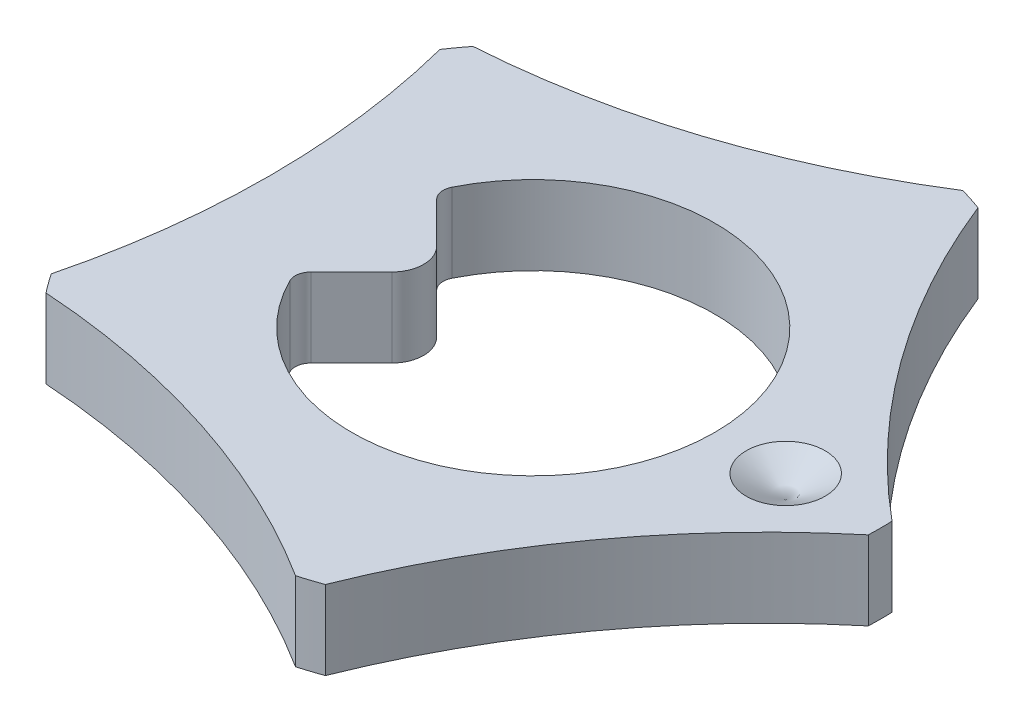
from build123d import *

# Parameters (mm, degrees)
SKETCH2_R           = 2.2
BOSS_EXTRUDE2_DEPTH = 0.5
SKETCH3_OUTSIDE_W   = 7.648
SKETCH3_OUTSIDE_H   = 7.648
CUT_EXTRUDE1_DEPTH  = 0.5
CUT_EXTRUDE2_REACH  = 2.5
FILLET1_R           = 0.2
FILLET2_R           = 0.1


with BuildPart() as part:
    # Sketch2 → Boss-Extrude2 (new body)
    with BuildSketch(Plane(origin=(0, 0, 0), x_dir=(1, 0, 0), z_dir=(0, 1, 0))):
        Circle(SKETCH2_R)
    extrude(amount=BOSS_EXTRUDE2_DEPTH)

    # Sketch3 outside → Cut-Extrude1 (cut)
    with BuildSketch(Plane(origin=(0, 0.5, 0), x_dir=(1, 0, 0), z_dir=(0, 1, 0))):
        Rectangle(SKETCH3_OUTSIDE_W, SKETCH3_OUTSIDE_H)
        with BuildLine():
            ThreePointArc((0.750757799, 2.067936829), (1.350081886, 0.980891906), (2.198721715, 0.074985473))
            ThreePointArc((2.198721715, 0.074985473), (2.2, 0), (2.198721715, -0.074985473))
            ThreePointArc((2.198721715, -0.074985473), (1.350081886, -0.980891906), (0.750757799, -2.067936829))
            ThreePointArc((0.750757799, -2.067936829), (0.679837388, -2.092324336), (0.608126953, -2.1142804))
            ThreePointArc((0.608126953, -2.1142804), (-0.515685393, -1.587116444), (-1.734727878, -1.35304072))
            ThreePointArc((-1.734727878, -1.35304072), (-1.779837388, -1.293127555), (-1.822878589, -1.231711675))
            ThreePointArc((-1.822878589, -1.231711675), (-1.668792986, 0), (-1.822878589, 1.231711675))
            ThreePointArc((-1.822878589, 1.231711675), (-1.779837388, 1.293127555), (-1.734727878, 1.35304072))
            ThreePointArc((-1.734727878, 1.35304072), (-0.515685393, 1.587116444), (0.608126953, 2.1142804))
            ThreePointArc((0.608126953, 2.1142804), (0.679837388, 2.092324336), (0.750757799, 2.067936829))
        make_face(mode=Mode.SUBTRACT)
    extrude(amount=-CUT_EXTRUDE1_DEPTH, mode=Mode.SUBTRACT)

    # Sketch4 → Cut-Extrude2 (cut, up to next)
    with BuildSketch(Plane(origin=(0, 0.5, 0), x_dir=(1, 0, 0), z_dir=(0, 1, 0)), mode=Mode.PRIVATE) as cut_extrude2_sk1:
        with BuildLine():
            Line((-1.059401619, 0.447401619), (-0.612, 0))
            Line((-0.612, 0), (-1.059401619, -0.447401619))
            ThreePointArc((-1.059401619, -0.447401619), (1.15, 0), (-1.059401619, 0.447401619))
        make_face()
    cut_extrude2_tool1 = extrude(cut_extrude2_sk1.sketch, amount=-CUT_EXTRUDE2_REACH, mode=Mode.PRIVATE) & part.part
    add(cut_extrude2_tool1.solids().sort_by_distance((0.062027, 0.5, 0))[0], mode=Mode.SUBTRACT)

    # Fillet1
    fillet1_edges = [part.edges().sort_by_distance(p)[0] for p in [
        (-0.612, 0.25, 0),
    ]]
    fillet(fillet1_edges, radius=FILLET1_R)

    # Fillet2
    fillet2_edges = [part.edges().sort_by_distance(p)[0] for p in [
        (-1.059401619, 0.25, -0.447401619),
        (-1.059401619, 0.25, 0.447401619),
    ]]
    fillet(fillet2_edges, radius=FILLET2_R)

    # Sketch6 → Cut-Revolve7 (revolve, cut)
    with BuildSketch(Plane.XY):
        Polygon((1.6, 0.5), (1.6, 0.355662433), (1.85, 0.5), align=None)
    revolve(axis=Axis((1.6, 0.5, 0), (0, -1, 0)), mode=Mode.SUBTRACT)


solid = part.part
